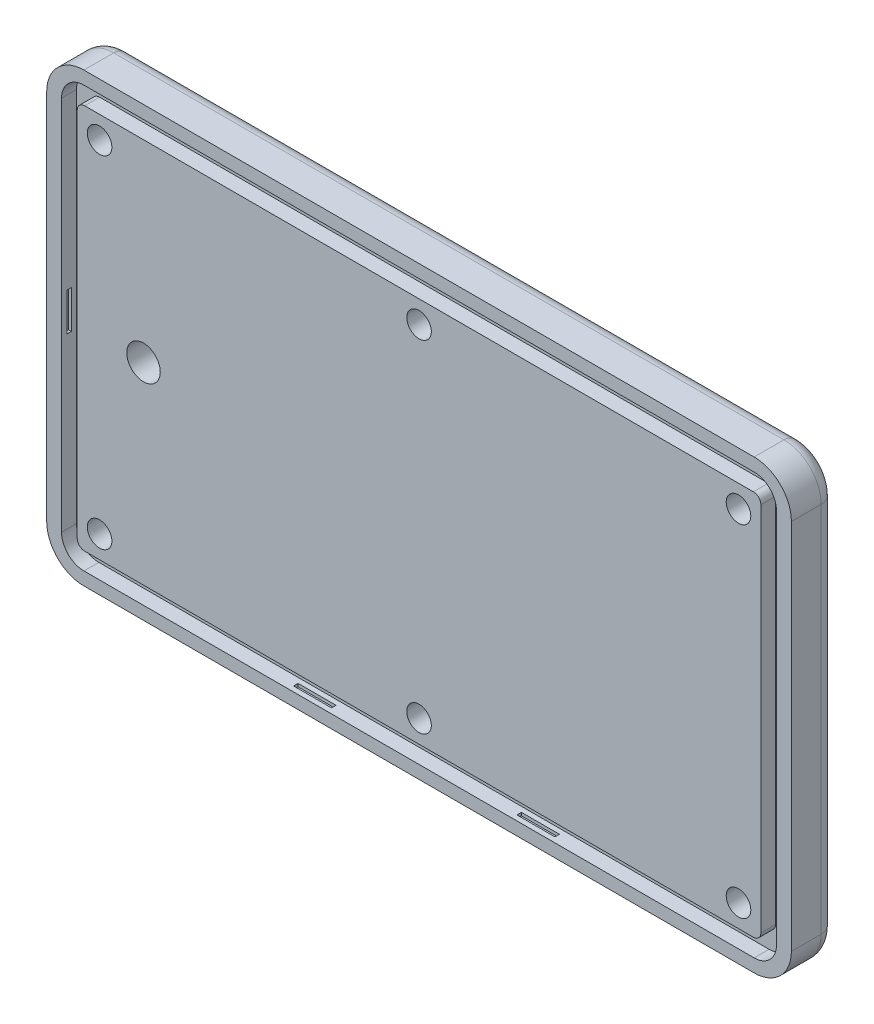
from build123d import *

# Parameters (mm, degrees)
SKETCH_1_W          = 100
SKETCH_1_H          = 60
EXTRUDE_1_DEPTH     = 6
FILLET_1_R          = 5
FILLET_2_R          = 2
CUT_EXTRUDE_1_DEPTH = 2
SKETCH_4_W          = 5.1
SKETCH_4_H          = 0.6
CUT_EXTRUDE_2_DEPTH = 0.4
SKETCH_5_W          = 5.1
SKETCH_5_H          = 0.6
CUT_EXTRUDE_3_DEPTH = 0.4
SKETCH_6_W          = 0.6
SKETCH_6_H          = 5.1
CUT_EXTRUDE_4_DEPTH = 0.4
SKETCH_7_W          = 0.6
SKETCH_7_H          = 5.1
CUT_EXTRUDE_5_DEPTH = 0.4
EXTRUDE_2_DEPTH     = 2
CUT_EXTRUDE_6_REACH = 8
SKETCH_9_R          = 1.65
SKETCH_10_R         = 3.05
CUT_EXTRUDE_7_DEPTH = 1.1
FILLET_3_R          = 0.5
CUT_EXTRUDE_8_REACH = 8
SKETCH_11_R         = 2.25


with BuildPart() as part:
    # 草图1 → 凸台-拉伸1 (new body)
    with BuildSketch(Plane.XY):
        Rectangle(SKETCH_1_W, SKETCH_1_H)
    extrude(amount=EXTRUDE_1_DEPTH)

    # 圆角1
    fillet_1_edges = [part.edges().sort_by_distance(p)[0] for p in [
        (-50, 30, 3),
        (50, 30, 3),
        (50, -30, 3),
        (-50, -30, 3),
    ]]
    fillet(fillet_1_edges, radius=FILLET_1_R)

    # 圆角2
    fillet_2_edges = [part.edges().sort_by_distance(p)[0] for p in [
        (0, -30, 0),
        (-50, 0, 0),
        (0, 30, 0),
        (50, 0, 0),
        (-48.535533906, 28.535533906, 0),
        (48.535533906, 28.535533906, 0),
        (48.535533906, -28.535533906, 0),
        (-48.535533906, -28.535533906, 0),
    ]]
    fillet(fillet_2_edges, radius=FILLET_2_R)

    # 草图2 → 切除-拉伸1 (cut)
    with BuildSketch(Plane.XY.offset(6)):
        with BuildLine():
            Line((-45, 28.25), (45, 28.25))
            ThreePointArc((45, 28.25), (47.121320344, 27.371320344), (48, 25.25))
            Line((48, 25.25), (48, -25.25))
            ThreePointArc((48, -25.25), (47.121320344, -27.371320344), (45, -28.25))
            Line((45, -28.25), (-45, -28.25))
            ThreePointArc((-45, -28.25), (-47.121320344, -27.371320344), (-48, -25.25))
            Line((-48, -25.25), (-48, 25.25))
            ThreePointArc((-48, 25.25), (-47.121320344, 27.371320344), (-45, 28.25))
        make_face()
    extrude(amount=-CUT_EXTRUDE_1_DEPTH, mode=Mode.SUBTRACT)

    # 草图4 → 切除-拉伸2 (cut)
    with BuildSketch(Plane(origin=(0, -28.25, 0), x_dir=(1, 0, 0), z_dir=(0, 1, 0))):
        with Locations((15, -5)):
            Rectangle(SKETCH_4_W, SKETCH_4_H)
        with Locations((-15, -5)):
            Rectangle(SKETCH_4_W, SKETCH_4_H)
    extrude(amount=-CUT_EXTRUDE_2_DEPTH, mode=Mode.SUBTRACT)

    # 草图5 → 切除-拉伸3 (cut)
    with BuildSketch(Plane.XZ.offset(-28.25)):
        with Locations((-15, 5)):
            Rectangle(SKETCH_5_W, SKETCH_5_H)
        with Locations((15, 5)):
            Rectangle(SKETCH_5_W, SKETCH_5_H)
    extrude(amount=-CUT_EXTRUDE_3_DEPTH, mode=Mode.SUBTRACT)

    # 草图6 → 切除-拉伸4 (cut)
    with BuildSketch(Plane(origin=(-48, 0, 0), x_dir=(0, 0, -1), z_dir=(1, 0, 0))):
        with Locations((-5, 0)):
            Rectangle(SKETCH_6_W, SKETCH_6_H)
    extrude(amount=-CUT_EXTRUDE_4_DEPTH, mode=Mode.SUBTRACT)

    # 草图7 → 切除-拉伸5 (cut)
    with BuildSketch(Plane.ZY.offset(-48)):
        with Locations((5, 0)):
            Rectangle(SKETCH_7_W, SKETCH_7_H)
    extrude(amount=-CUT_EXTRUDE_5_DEPTH, mode=Mode.SUBTRACT)

    # 草图8 → 凸台-拉伸2 (add)
    with BuildSketch(Plane.XY.offset(4)):
        with BuildLine():
            Line((44.9, -25.9), (-44.9, -25.9))
            ThreePointArc((-44.9, -25.9), (-45.607106781, -25.607106781), (-45.9, -24.9))
            Line((-45.9, -24.9), (-45.9, 24.9))
            ThreePointArc((-45.9, 24.9), (-45.607106781, 25.607106781), (-44.9, 25.9))
            Line((-44.9, 25.9), (44.9, 25.9))
            ThreePointArc((44.9, 25.9), (45.607106781, 25.607106781), (45.9, 24.9))
            Line((45.9, 24.9), (45.9, -24.9))
            ThreePointArc((45.9, -24.9), (45.607106781, -25.607106781), (44.9, -25.9))
        make_face()
    extrude(amount=EXTRUDE_2_DEPTH)

    # 草图9 → 切除-拉伸6 (cut, up to next)
    with BuildSketch(Plane.XY.offset(6), mode=Mode.PRIVATE) as cut_extrude_6_sk1:
        with Locations((42.9, 22.9)):
            Circle(SKETCH_9_R)
    cut_extrude_6_tool1 = extrude(cut_extrude_6_sk1.sketch, amount=-CUT_EXTRUDE_6_REACH, mode=Mode.PRIVATE) & part.part
    add(cut_extrude_6_tool1.solids().sort_by_distance((42.9, 22.9, 6))[0], mode=Mode.SUBTRACT)
    # 草图9 → 切除-拉伸6 (cut, up to next)
    with BuildSketch(Plane.XY.offset(6), mode=Mode.PRIVATE) as cut_extrude_6_sk2:
        with Locations((0, 22.9)):
            Circle(SKETCH_9_R)
    cut_extrude_6_tool2 = extrude(cut_extrude_6_sk2.sketch, amount=-CUT_EXTRUDE_6_REACH, mode=Mode.PRIVATE) & part.part
    add(cut_extrude_6_tool2.solids().sort_by_distance((0, 22.9, 6))[0], mode=Mode.SUBTRACT)
    # 草图9 → 切除-拉伸6 (cut, up to next)
    with BuildSketch(Plane.XY.offset(6), mode=Mode.PRIVATE) as cut_extrude_6_sk3:
        with Locations((-42.9, 22.9)):
            Circle(SKETCH_9_R)
    cut_extrude_6_tool3 = extrude(cut_extrude_6_sk3.sketch, amount=-CUT_EXTRUDE_6_REACH, mode=Mode.PRIVATE) & part.part
    add(cut_extrude_6_tool3.solids().sort_by_distance((-42.9, 22.9, 6))[0], mode=Mode.SUBTRACT)
    # 草图9 → 切除-拉伸6 (cut, up to next)
    with BuildSketch(Plane.XY.offset(6), mode=Mode.PRIVATE) as cut_extrude_6_sk4:
        with Locations((-42.9, -22.9)):
            Circle(SKETCH_9_R)
    cut_extrude_6_tool4 = extrude(cut_extrude_6_sk4.sketch, amount=-CUT_EXTRUDE_6_REACH, mode=Mode.PRIVATE) & part.part
    add(cut_extrude_6_tool4.solids().sort_by_distance((-42.9, -22.9, 6))[0], mode=Mode.SUBTRACT)
    # 草图9 → 切除-拉伸6 (cut, up to next)
    with BuildSketch(Plane.XY.offset(6), mode=Mode.PRIVATE) as cut_extrude_6_sk5:
        with Locations((0, -22.9)):
            Circle(SKETCH_9_R)
    cut_extrude_6_tool5 = extrude(cut_extrude_6_sk5.sketch, amount=-CUT_EXTRUDE_6_REACH, mode=Mode.PRIVATE) & part.part
    add(cut_extrude_6_tool5.solids().sort_by_distance((0, -22.9, 6))[0], mode=Mode.SUBTRACT)
    # 草图9 → 切除-拉伸6 (cut, up to next)
    with BuildSketch(Plane.XY.offset(6), mode=Mode.PRIVATE) as cut_extrude_6_sk6:
        with Locations((42.9, -22.9)):
            Circle(SKETCH_9_R)
    cut_extrude_6_tool6 = extrude(cut_extrude_6_sk6.sketch, amount=-CUT_EXTRUDE_6_REACH, mode=Mode.PRIVATE) & part.part
    add(cut_extrude_6_tool6.solids().sort_by_distance((42.9, -22.9, 6))[0], mode=Mode.SUBTRACT)

    # 草图10 → 切除-拉伸7 (cut)
    with BuildSketch(Plane(origin=(0, 0, 0), x_dir=(-1, 0, 0), z_dir=(0, 0, -1))):
        with Locations((42.9, 22.9)):
            Circle(SKETCH_10_R)
        with Locations((0, 22.9)):
            Circle(SKETCH_10_R)
        with Locations((-42.9, 22.9)):
            Circle(SKETCH_10_R)
        with Locations((-42.9, -22.9)):
            Circle(SKETCH_10_R)
        with Locations((0, -22.9)):
            Circle(SKETCH_10_R)
        with Locations((42.9, -22.9)):
            Circle(SKETCH_10_R)
    extrude(amount=-CUT_EXTRUDE_7_DEPTH, mode=Mode.SUBTRACT)

    # 圆角3
    fillet_3_edges = [part.edges().sort_by_distance(p)[0] for p in [
        (-39.85, -22.9, 0),
        (3.05, -22.9, 0),
        (45.95, -22.9, 0),
        (45.95, 22.9, 0),
        (3.05, 22.9, 0),
        (-39.85, 22.9, 0),
    ]]
    fillet(fillet_3_edges, radius=FILLET_3_R)

    # 草图11 → 切除-拉伸8 (cut, up to next)
    with BuildSketch(Plane.XY.offset(6), mode=Mode.PRIVATE) as cut_extrude_8_sk1:
        with Locations((-37, 0)):
            Circle(SKETCH_11_R)
    cut_extrude_8_tool1 = extrude(cut_extrude_8_sk1.sketch, amount=-CUT_EXTRUDE_8_REACH, mode=Mode.PRIVATE) & part.part
    add(cut_extrude_8_tool1.solids().sort_by_distance((-37, 0, 6))[0], mode=Mode.SUBTRACT)


solid = part.part
